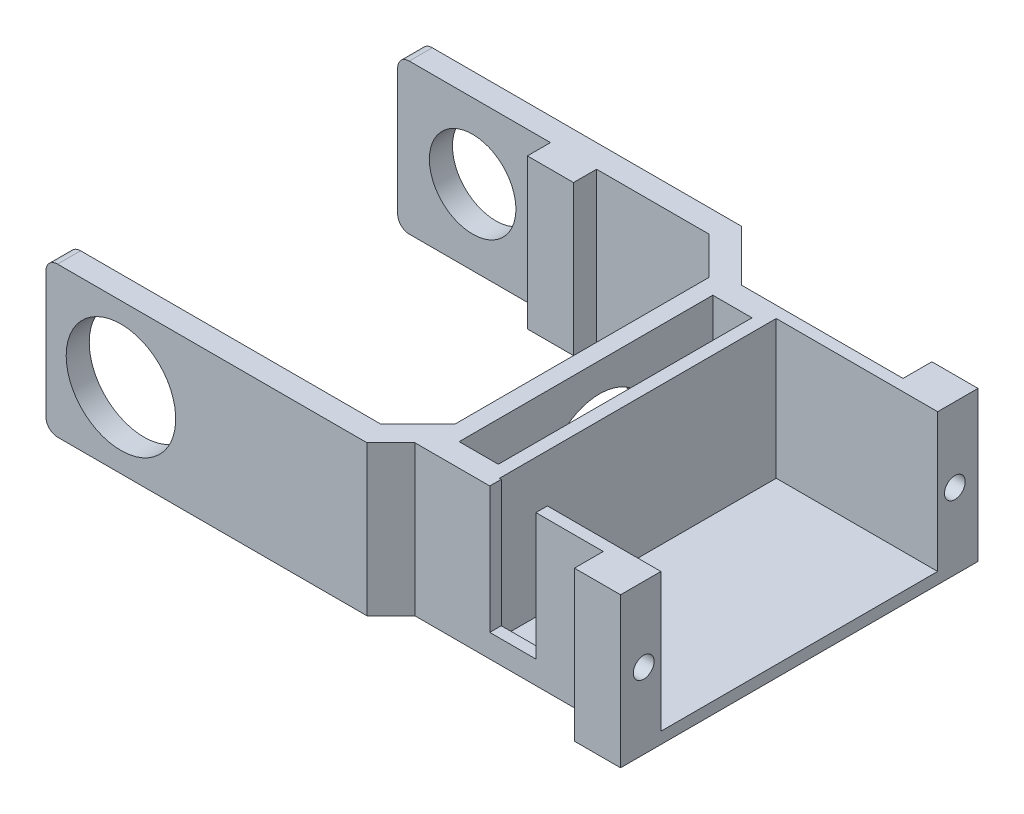
from build123d import *

# Parameters (mm, degrees)
P_IDAT_VYSUNUT_M1_DEPTH   = 13
ZAOBLIT1_R                = 1
SKICA6_R                  = 3.75
ODEBRAT_VYSUNUT_M4_DEPTH  = 5
SKICA7_R                  = 4.75
ODEBRAT_VYSUNUT_M5_DEPTH  = 5
P_IDAT_VYSUNUT_M2_DEPTH   = 13
SKICA9_W                  = 3.4
SKICA9_H                  = 22
ODEBRAT_VYSUNUT_M6_DEPTH  = 14
SKICA10_W                 = 14
SKICA10_H                 = 24
ODEBRAT_VYSUNUT_M7_DEPTH  = 12
SKICA11_W                 = 2.5
SKICA11_H                 = 13
P_IDAT_VYSUNUT_M3_DEPTH   = 4
SKICA12_R                 = 0.9
ODEBRAT_VYSUNUT_M8_DEPTH  = 4
SKICA13_W                 = 4
SKICA13_H                 = 11
ODEBRAT_VYSUNUT_M9_DEPTH  = 4
SKICA14_R                 = 4.5
ODEBRAT_VYSUNUT_M10_DEPTH = 4
SKICA15_W                 = 4
SKICA15_H                 = 2
P_IDAT_VYSUNUT_M4_DEPTH   = 13


with BuildPart() as part:
    # Skica1 → Přidat vysunutím1 (new body)
    with BuildSketch(Plane(origin=(0, 0, 0), x_dir=(1, 0, 0), z_dir=(0, 1, 0))):
        Polygon((0, -11), (0, 11), (-3.25, 14.25), (-30.25, 14.25), (-30.25, 16.25), (-2.421572875, 16.25), (2, 11.828427125), (2, -11.828427125), (-2.421572875, -16.25), (-30.25, -16.25), (-30.25, -14.25), (-3.25, -14.25), align=None)
    extrude(amount=P_IDAT_VYSUNUT_M1_DEPTH)

    # Zaoblit1
    zaoblit1_edges = [part.edges().sort_by_distance(p)[0] for p in [
        (-30.25, 0, -15.25),
        (-30.25, 0, 15.25),
        (-30.25, 13, 15.25),
        (-30.25, 13, -15.25),
    ]]
    fillet(zaoblit1_edges, radius=ZAOBLIT1_R)

    # Skica6 → Odebrat vysunutím4 (cut)
    with BuildSketch(Plane(origin=(0, 0, -16.25), x_dir=(-1, 0, 0), z_dir=(0, 0, -1))):
        with Locations((23.75, 6.5)):
            Circle(SKICA6_R)
    extrude(amount=-ODEBRAT_VYSUNUT_M4_DEPTH, mode=Mode.SUBTRACT)

    # Skica7 → Odebrat vysunutím5 (cut)
    with BuildSketch(Plane(origin=(0, 0, 14.25), x_dir=(-1, 0, 0), z_dir=(0, 0, -1))):
        with Locations((23.75, 6.5)):
            Circle(SKICA7_R)
    extrude(amount=-ODEBRAT_VYSUNUT_M5_DEPTH, mode=Mode.SUBTRACT)

    # Skica8 → Přidat vysunutím2 (add)
    with BuildSketch(Plane.XZ):
        Polygon((-0.343145751, 14.171572875), (20, 14.171572875), (20, -11.828427125), (2, -11.828427125), (2, 11.828427125), align=None)
    extrude(amount=-P_IDAT_VYSUNUT_M2_DEPTH)

    # Skica9 → Odebrat vysunutím6 (cut, through all)
    with BuildSketch(Plane(origin=(0, 13, 0), x_dir=(1, 0, 0), z_dir=(0, 1, 0))):
        with Locations((3.2, -1.171572875)):
            Rectangle(SKICA9_W, SKICA9_H)
    extrude(amount=-ODEBRAT_VYSUNUT_M6_DEPTH, mode=Mode.SUBTRACT)

    # Skica10 → Odebrat vysunutím7 (cut)
    with BuildSketch(Plane(origin=(0, 13, 0), x_dir=(1, 0, 0), z_dir=(0, 1, 0))):
        with Locations((13, -1.171572875)):
            Rectangle(SKICA10_W, SKICA10_H)
    extrude(amount=-ODEBRAT_VYSUNUT_M7_DEPTH, mode=Mode.SUBTRACT)

    # Skica11 → Přidat vysunutím3 (add)
    with BuildSketch(Plane(origin=(20, 0, 0), x_dir=(0, 0, -1), z_dir=(1, 0, 0))):
        with Locations((-15.421572875, 6.5)):
            Rectangle(SKICA11_W, SKICA11_H)
        with Locations((13.078427125, 6.5)):
            Rectangle(SKICA11_W, SKICA11_H)
    extrude(amount=-P_IDAT_VYSUNUT_M3_DEPTH)

    # Skica12 → Odebrat vysunutím8 (cut)
    with BuildSketch(Plane(origin=(20, 0, 0), x_dir=(0, 0, -1), z_dir=(1, 0, 0))):
        with Locations((-14.665360427, 6.555058558)):
            Circle(SKICA12_R)
        with Locations((12.322113705, 6.555061415)):
            Circle(SKICA12_R)
    extrude(amount=-ODEBRAT_VYSUNUT_M8_DEPTH, mode=Mode.SUBTRACT)

    # Skica13 → Odebrat vysunutím9 (cut)
    with BuildSketch(Plane.XY.offset(14.171572875)):
        with Locations((8.156854249, 7.5)):
            Rectangle(SKICA13_W, SKICA13_H)
    extrude(amount=-ODEBRAT_VYSUNUT_M9_DEPTH, mode=Mode.SUBTRACT)

    # Skica14 → Odebrat vysunutím10 (cut)
    with BuildSketch(Plane.ZY):
        with Locations((0, 6)):
            Circle(SKICA14_R)
    extrude(amount=-ODEBRAT_VYSUNUT_M10_DEPTH, mode=Mode.SUBTRACT)

    # Skica15 → Přidat vysunutím4 (add)
    with BuildSketch(Plane(origin=(0, 13, 0), x_dir=(1, 0, 0), z_dir=(0, 1, 0))):
        with Locations((-15, 13.25)):
            Rectangle(SKICA15_W, SKICA15_H)
    extrude(amount=-P_IDAT_VYSUNUT_M4_DEPTH)


solid = part.part
